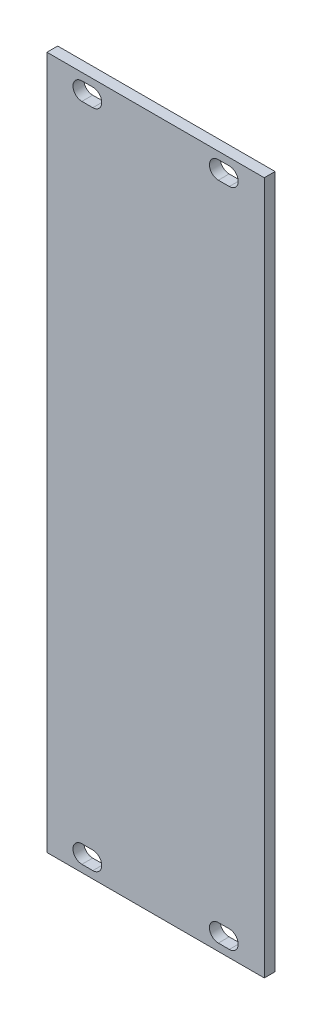
from build123d import *

# Parameters (mm, degrees)
SKETCH1_W           = 40.3
SKETCH1_H           = 128.5
BOSS_EXTRUDE1_DEPTH = 2


with BuildPart() as part:
    # Sketch1 → Boss-Extrude1 (new body)
    with BuildSketch(Plane.XY):
        Rectangle(SKETCH1_W, SKETCH1_H)
        with BuildLine():
            Line((-13.666, -59.6), (-11.634, -59.6))
            ThreePointArc((-11.634, -59.6), (-9.984, -61.25), (-11.634, -62.9))
            Line((-11.634, -62.9), (-13.666, -62.9))
            ThreePointArc((-13.666, -62.9), (-15.316, -61.25), (-13.666, -59.6))
        make_face(mode=Mode.SUBTRACT)
        with BuildLine():
            Line((-13.666, 62.9), (-11.634, 62.9))
            ThreePointArc((-11.634, 62.9), (-9.984, 61.25), (-11.634, 59.6))
            Line((-11.634, 59.6), (-13.666, 59.6))
            ThreePointArc((-13.666, 59.6), (-15.316, 61.25), (-13.666, 62.9))
        make_face(mode=Mode.SUBTRACT)
        with BuildLine():
            Line((11.634000014, 62.9), (13.666000014, 62.9))
            ThreePointArc((13.666000014, 62.9), (15.316000014, 61.25), (13.666000014, 59.6))
            Line((13.666000014, 59.6), (11.634000014, 59.6))
            ThreePointArc((11.634000014, 59.6), (9.984000014, 61.25), (11.634000014, 62.9))
        make_face(mode=Mode.SUBTRACT)
        with BuildLine():
            Line((11.634000014, -59.6), (13.666000014, -59.6))
            ThreePointArc((13.666000014, -59.6), (15.316000014, -61.25), (13.666000014, -62.9))
            Line((13.666000014, -62.9), (11.634000014, -62.9))
            ThreePointArc((11.634000014, -62.9), (9.984000014, -61.25), (11.634000014, -59.6))
        make_face(mode=Mode.SUBTRACT)
    extrude(amount=BOSS_EXTRUDE1_DEPTH)


solid = part.part
